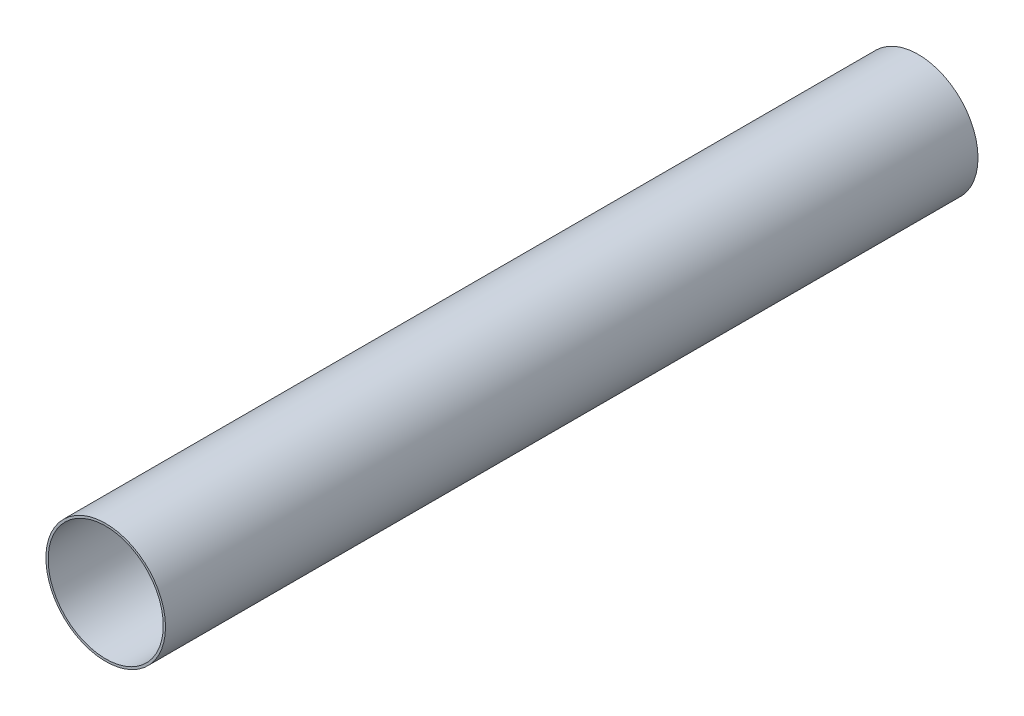
from build123d import *

# Parameters (mm, degrees)
SKETCH1_R           = 67.31
SKETCH1_R_2         = 64.77
BOSS_EXTRUDE1_DEPTH = 914.4


with BuildPart() as part:
    # Sketch1 → Boss-Extrude1 (new body)
    with BuildSketch(Plane.XY):
        Circle(SKETCH1_R)
        Circle(SKETCH1_R_2, mode=Mode.SUBTRACT)
    extrude(amount=BOSS_EXTRUDE1_DEPTH)


solid = part.part
